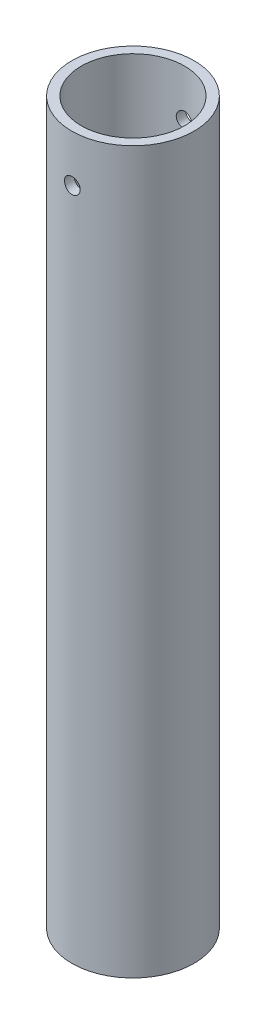
from build123d import *

# Parameters (mm, degrees)
SKETCH_1_R               = 19.5
SKETCH_1_R_2             = 16.5
EXTRUDE_1_DEPTH          = 230
SKETCH_2_R               = 2.5
CUT_EXTRUDE_1_DEPTH      = 20.5
CUT_EXTRUDE_1_DEPTH_BACK = 20.5


with BuildPart() as part:
    # 草图1 → 凸台-拉伸1 (new body)
    with BuildSketch(Plane(origin=(0, 0, 0), x_dir=(1, 0, 0), z_dir=(0, 1, 0))):
        Circle(SKETCH_1_R)
        Circle(SKETCH_1_R_2, mode=Mode.SUBTRACT)
    extrude(amount=EXTRUDE_1_DEPTH)

    # 草图2 → 切除-拉伸1 (cut, two sides)
    with BuildSketch(Plane.XY) as cut_extrude_1_sk:
        with Locations((0, 215)):
            Circle(SKETCH_2_R)
    extrude(amount=CUT_EXTRUDE_1_DEPTH, mode=Mode.SUBTRACT)
    extrude(cut_extrude_1_sk.sketch, amount=-CUT_EXTRUDE_1_DEPTH_BACK, mode=Mode.SUBTRACT)


solid = part.part
